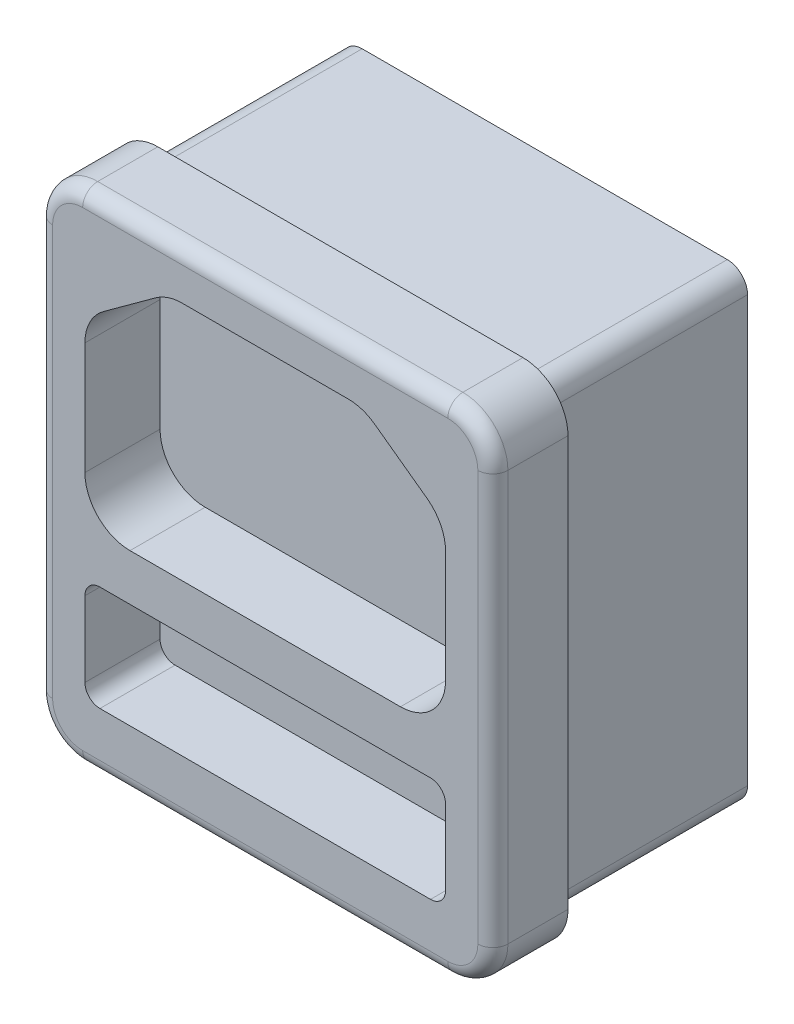
from build123d import *

# Parameters (mm, degrees)
BOSS_EXTRUDE1_DEPTH = 5
FILLET3_R           = 1
BOSS_EXTRUDE2_DEPTH = 13.6


with BuildPart() as part:
    # Sketch1 → Boss-Extrude1 (new body)
    with BuildSketch(Plane.XY):
        with BuildLine():
            Line((-12.15, -16.65), (12.15, -16.65))
            ThreePointArc((12.15, -16.65), (14.271320344, -15.771320344), (15.15, -13.65))
            Line((15.15, -13.65), (15.15, 13.65))
            ThreePointArc((15.15, 13.65), (14.271320344, 15.771320344), (12.15, 16.65))
            Line((12.15, 16.65), (-12.15, 16.65))
            ThreePointArc((-12.15, 16.65), (-14.271320344, 15.771320344), (-15.15, 13.65))
            Line((-15.15, 13.65), (-15.15, -13.65))
            ThreePointArc((-15.15, -13.65), (-14.271320344, -15.771320344), (-12.15, -16.65))
        make_face()
        with BuildLine():
            Line((-5.524448559, 13.45), (5.524448559, 13.45))
            ThreePointArc((5.524448559, 13.45), (6.452181075, 13.302948016), (7.288963652, 12.876208253))
            Line((7.288963652, 12.876208253), (10.764515093, 10.348534478))
            ThreePointArc((10.764515093, 10.348534478), (11.673344841, 9.28365916), (12, 7.922326225))
            Line((12, 7.922326225), (12, 0.45))
            ThreePointArc((12, 0.45), (11.121320344, -1.671320344), (9, -2.55))
            Line((9, -2.55), (-9, -2.55))
            ThreePointArc((-9, -2.55), (-11.121320344, -1.671320344), (-12, 0.45))
            Line((-12, 0.45), (-12, 7.922326225))
            ThreePointArc((-12, 7.922326225), (-11.673344841, 9.28365916), (-10.764515093, 10.348534478))
            Line((-10.764515093, 10.348534478), (-7.288963652, 12.876208253))
            ThreePointArc((-7.288963652, 12.876208253), (-6.452181075, 13.302948016), (-5.524448559, 13.45))
        make_face(mode=Mode.SUBTRACT)
        with BuildLine():
            Line((-12, -6.65), (-12, -11.65))
            ThreePointArc((-12, -11.65), (-11.707106781, -12.357106781), (-11, -12.65))
            Line((-11, -12.65), (11, -12.65))
            ThreePointArc((11, -12.65), (11.707106781, -12.357106781), (12, -11.65))
            Line((12, -11.65), (12, -6.65))
            ThreePointArc((12, -6.65), (11.707106781, -5.942893219), (11, -5.65))
            Line((11, -5.65), (-11, -5.65))
            ThreePointArc((-11, -5.65), (-11.707106781, -5.942893219), (-12, -6.65))
        make_face(mode=Mode.SUBTRACT)
    extrude(amount=BOSS_EXTRUDE1_DEPTH)

    # Fillet3
    fillet3_edges = [part.edges().sort_by_distance(p)[0] for p in [
        (-14.271320344, 15.771320344, 5),
        (-15.15, 0, 5),
        (-14.271320344, -15.771320344, 5),
        (0, -16.65, 5),
        (14.271320344, -15.771320344, 5),
        (15.15, 0, 5),
        (14.271320344, 15.771320344, 5),
        (0, 16.65, 5),
    ]]
    fillet(fillet3_edges, radius=FILLET3_R)

    # Sketch3 → Boss-Extrude2 (add)
    with BuildSketch(Plane(origin=(0, 0, 0), x_dir=(-1, 0, 0), z_dir=(0, 0, -1))):
        with BuildLine():
            Line((-13.5, 14.15), (-13.5, -14.15))
            ThreePointArc((-13.5, -14.15), (-13.104594155, -15.104594155), (-12.15, -15.5))
            Line((-12.15, -15.5), (12.15, -15.5))
            ThreePointArc((12.15, -15.5), (13.104594155, -15.104594155), (13.5, -14.15))
            Line((13.5, -14.15), (13.5, 14.15))
            ThreePointArc((13.5, 14.15), (13.104594155, 15.104594155), (12.15, 15.5))
            Line((12.15, 15.5), (-12.15, 15.5))
            ThreePointArc((-12.15, 15.5), (-13.104594155, 15.104594155), (-13.5, 14.15))
        make_face()
    extrude(amount=BOSS_EXTRUDE2_DEPTH)


solid = part.part
